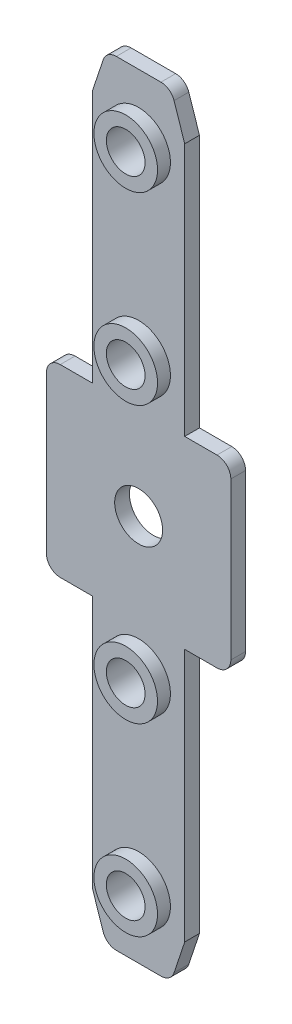
from build123d import *

# Parameters (mm, degrees)
SKETCH1_R             = 2.6
BOSS_EXTRUDE1_DEPTH   = 1.6
SKETCH2_R             = 3.45
BOSS_EXTRUDE2_DEPTH   = 1.4
M5X0_8_TAPPED_HOLE1_D = 4.2


with BuildPart() as part:
    # Sketch1 → Boss-Extrude1 (new body)
    with BuildSketch(Plane.XY):
        with BuildLine():
            Line((-10, -8.5), (-10, 8.5))
            ThreePointArc((-10, 8.5), (-9.560660172, 9.560660172), (-8.5, 10))
            Line((-8.5, 10), (-5, 10))
            Line((-5, 10), (-5, 37.485))
            Line((-5, 37.485), (-3.841886117, 40.959341649))
            ThreePointArc((-3.841886117, 40.959341649), (-3.295926597, 41.701863278), (-2.41886117, 41.985))
            Line((-2.41886117, 41.985), (2.41886117, 41.985))
            ThreePointArc((2.41886117, 41.985), (3.295926597, 41.701863278), (3.841886117, 40.959341649))
            Line((3.841886117, 40.959341649), (5, 37.485))
            Line((5, 37.485), (5, 10))
            Line((5, 10), (8.5, 10))
            ThreePointArc((8.5, 10), (9.560660172, 9.560660172), (10, 8.5))
            Line((10, 8.5), (10, -8.5))
            ThreePointArc((10, -8.5), (9.560660172, -9.560660172), (8.5, -10))
            Line((8.5, -10), (5, -10))
            Line((5, -10), (5, -37.485))
            Line((5, -37.485), (3.841886117, -40.959341649))
            ThreePointArc((3.841886117, -40.959341649), (3.295926597, -41.701863278), (2.41886117, -41.985))
            Line((2.41886117, -41.985), (-2.41886117, -41.985))
            ThreePointArc((-2.41886117, -41.985), (-3.295926597, -41.701863278), (-3.841886117, -40.959341649))
            Line((-3.841886117, -40.959341649), (-5, -37.485))
            Line((-5, -37.485), (-5, -10))
            Line((-5, -10), (-8.5, -10))
            ThreePointArc((-8.5, -10), (-9.560660172, -9.560660172), (-10, -8.5))
        make_face()
        Circle(SKETCH1_R, mode=Mode.SUBTRACT)
    extrude(amount=BOSS_EXTRUDE1_DEPTH)

    # Sketch2 → Boss-Extrude2 (add)
    with BuildSketch(Plane.XY.offset(1.6)):
        with Locations((0, 14.95)):
            Circle(SKETCH2_R)
        with Locations((0, 34.95)):
            Circle(SKETCH2_R)
        with Locations((0, -14.95)):
            Circle(SKETCH2_R)
        with Locations((0, -34.95)):
            Circle(SKETCH2_R)
    extrude(amount=BOSS_EXTRUDE2_DEPTH)

    # M5x0.8 Tapped Hole1 (through all)
    with Locations(Plane.XY.offset(3)):
        with Locations((0, 34.95), (0, 14.95), (0, -14.95), (0, -34.95)):
            Hole(M5X0_8_TAPPED_HOLE1_D / 2)


solid = part.part
